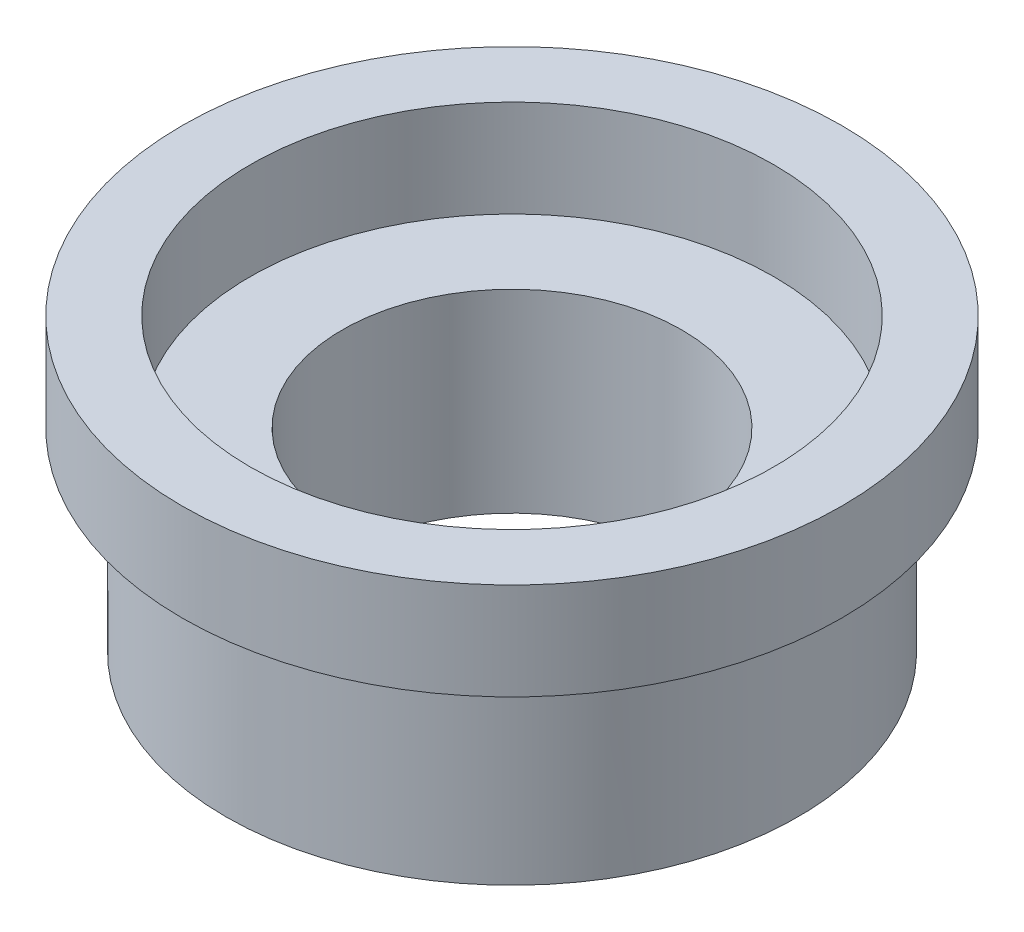
from build123d import *

# Parameters (mm, degrees)
SKETCH1_R           = 43.18
SKETCH1_R_2         = 34.29
BOSS_EXTRUDE1_DEPTH = 12.7
SKETCH2_R           = 37.465
SKETCH2_R_2         = 22.225
BOSS_EXTRUDE2_DEPTH = 25.4


with BuildPart() as part:
    # Sketch1 → Boss-Extrude1 (new body)
    with BuildSketch(Plane(origin=(0, 0, 0), x_dir=(1, 0, 0), z_dir=(0, 1, 0))):
        Circle(SKETCH1_R)
        Circle(SKETCH1_R_2, mode=Mode.SUBTRACT)
    extrude(amount=BOSS_EXTRUDE1_DEPTH)

    # Sketch2 → Boss-Extrude2 (add)
    with BuildSketch(Plane.XZ):
        Circle(SKETCH2_R)
        Circle(SKETCH2_R_2, mode=Mode.SUBTRACT)
    extrude(amount=BOSS_EXTRUDE2_DEPTH)


solid = part.part
